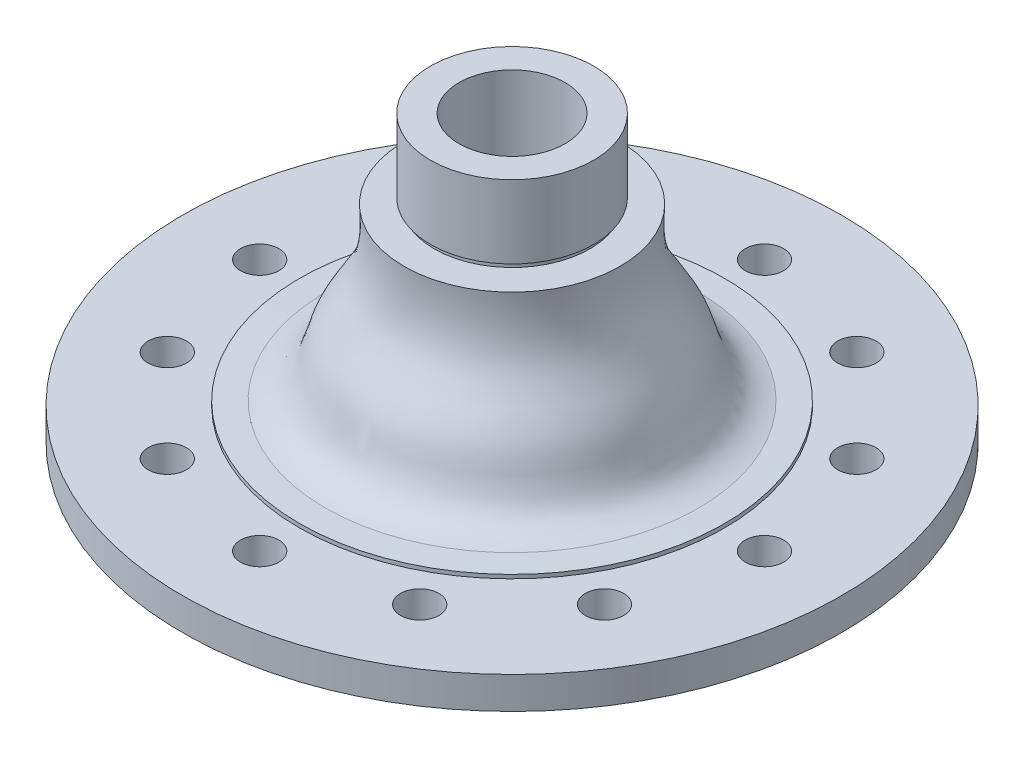
from build123d import *

# Parameters (mm, degrees)
SKETCH_3_W               = 24
SKETCH_3_H               = 17.528375635
SKETCH_4_R               = 10.5
CUT_EXTRUDE_1_DEPTH      = 30
PATTERN_CIRCULAR_1_COUNT = 12


with BuildPart() as part:
    # 草图2 → 旋转1 (revolve)
    with BuildSketch(Plane.XY):
        with BuildLine():
            Line((628.514440138, -27.938395666), (628.514440138, -67.388903254))
            Line((628.514440138, -67.388903254), (628.514440138, -106.839410841))
            Line((628.514440138, -106.839410841), (644.137468569, -106.839410841))
            Line((644.137468569, -106.839410841), (644.137468569, -156.607948671))
            Line((644.137468569, -156.607948671), (660.065119858, -156.607948671))
            add(Edge.make_bspline(
                [(660.065119858, -156.607948671), (663.097961625, -156.988826471), (667.510654429, -158.674715159), (674.04876802, -164.83793422), (674.645699136, -171.621615989), (673.724213488, -175.886758841)],
                knots=[0, 0, 0, 0, 2126.071479581, 3119.447228311, 6154.527529927, 6154.527529927, 6154.527529927, 6154.527529927], degree=3, weights=[1, 1, 1, 1, 1, 1]))
            ThreePointArc((673.724213488, -175.886758841), (678.502301213, -187.396306093), (681.053033074, -199.594402961))
            Line((681.053033074, -199.594402961), (681.141679927, -199.594402961))
            Line((681.141679927, -199.594402961), (718.926959628, -199.594402961))
            Line((718.926959628, -199.594402961), (718.926959628, -189.098920651))
            ThreePointArc((718.926959628, -189.098920651), (720.464553406, -185.386840898), (724.176633159, -183.849247119))
            Line((724.176633159, -183.849247119), (732.610849344, -183.849247119))
            Line((732.610849344, -183.849247119), (732.610849344, -166.320871484))
            Line((732.610849344, -166.320871484), (715.675420917, -166.320871484))
            Line((715.675420917, -166.320871484), (715.675420917, -164.221002072))
            Line((715.675420917, -164.221002072), (701.57964043, -163.876181958))
            add(Edge.make_bspline(
                [(701.57964043, -163.876181958), (696.836978513, -162.873820387), (682.485210268, -157.676172339), (679.945843963, -129.423738671), (658.481699004, -105.854615848), (657.726950227, -82.12575596), (658.548500632, -70.985718628)],
                knots=[0, 0, 0, 0, 1057.430308103, 2997.111062824, 5402.743204918, 7834.148234872, 7834.148234872, 7834.148234872, 7834.148234872], degree=3, weights=[1, 1, 1, 1, 1, 1, 1]))
            Line((658.548500632, -70.985718628), (642.037599156, -70.985718628))
            Line((642.037599156, -70.985718628), (642.037599156, -67.835914509))
            Line((642.037599156, -67.835914509), (644.13666516, -67.835914509))
            Line((644.13666516, -67.835914509), (644.13666516, -27.938395666))
            Line((644.13666516, -27.938395666), (628.514440138, -27.938395666))
        make_face()
        Polygon((733.66078405, -166.320871484), (732.610849344, -166.320871484), (732.610849344, -183.849247119), (755.709412884, -183.849247119), (755.709412884, -166.320871484), (754.659478178, -166.320871484), align=None)
    revolve(axis=Axis((599.514440138, -67.388903254, 0), (0, -1, 0)))

    # 草图3 → 旋转2 (revolve)
    with BuildSketch(Plane.XY):
        with Locations((431.319467391, -175.085059301)):
            Rectangle(SKETCH_3_W, SKETCH_3_H)
    revolve(axis=Axis((599.514440138, -67.835914509, 0), (0, 1, 0)))

    # 草图4 → 切除-拉伸1 (cut)
    with BuildSketch(Plane(origin=(0, -166.320871484, 0), x_dir=(1, 0, 0), z_dir=(0, 1, 0))):
        with Locations((461.514440138, 0)):
            Circle(SKETCH_4_R)
    cut_extrude_1 = extrude(amount=-CUT_EXTRUDE_1_DEPTH, mode=Mode.SUBTRACT)

    # 阵列(圆周)1: 切除-拉伸1 ×12 about axis
    pattern_circular_1_axis = Axis((599.514440138, 0, 0), (0, 1, 0))
    for i in range(1, PATTERN_CIRCULAR_1_COUNT):
        add(cut_extrude_1.rotate(pattern_circular_1_axis, i * 360 / PATTERN_CIRCULAR_1_COUNT), mode=Mode.SUBTRACT)


solid = part.part
